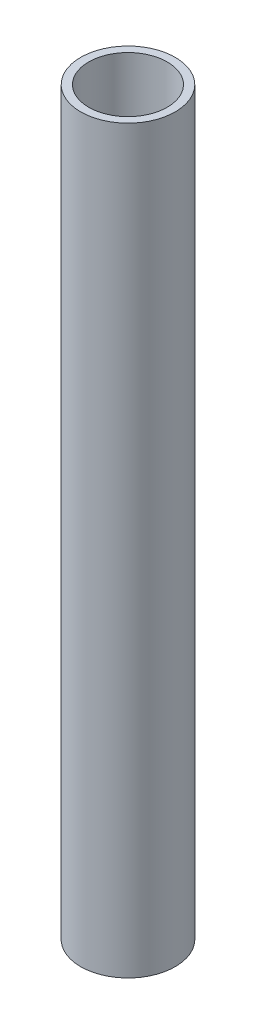
from build123d import *

# Parameters (mm, degrees)
SKETCH1_R           = 21.082
SKETCH1_R_2         = 17.526
BOSS_EXTRUDE1_DEPTH = 330.2


with BuildPart() as part:
    # Sketch1 → Boss-Extrude1 (new body)
    with BuildSketch(Plane(origin=(0, 0, 0), x_dir=(1, 0, 0), z_dir=(0, 1, 0))):
        Circle(SKETCH1_R)
        Circle(SKETCH1_R_2, mode=Mode.SUBTRACT)
    extrude(amount=BOSS_EXTRUDE1_DEPTH)


solid = part.part
